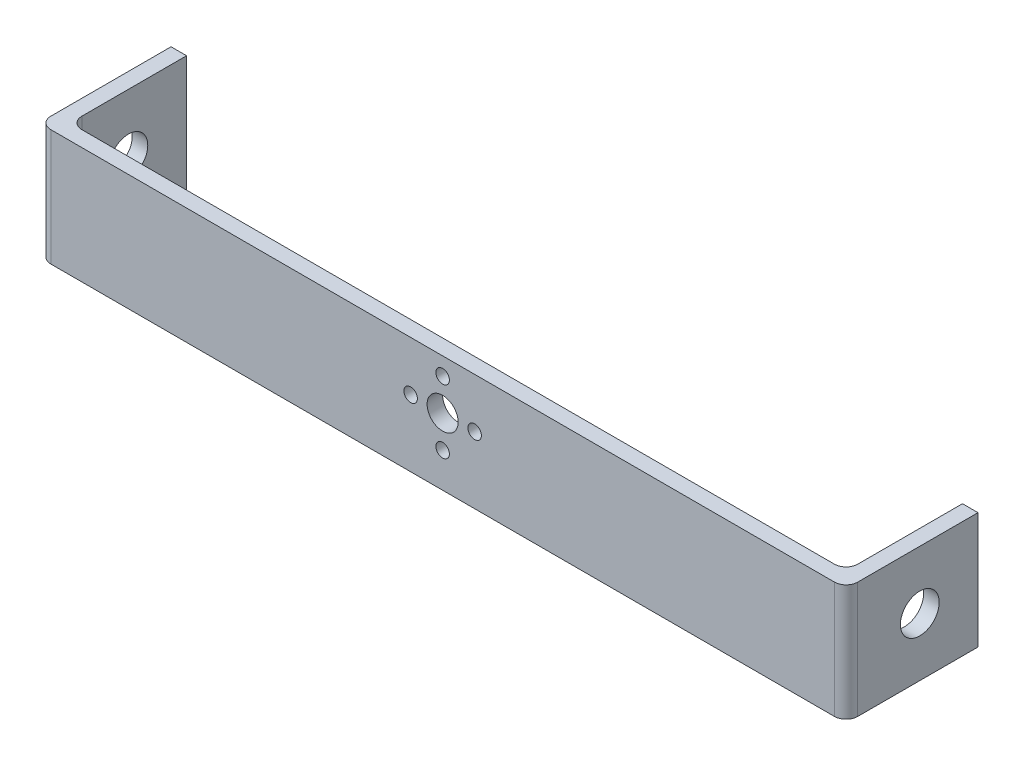
from build123d import *

# Parameters (mm, degrees)
SURFACE_EXTRUDE1_1_DEPTH = 30
THICKEN2_T2              = 4
SURFACE_EXTRUDE2_2_DEPTH = 20
THICKEN3_T2              = 4
FILLET1_R                = 3
SKETCH3_R                = 5
CUT_EXTRUDE1_DEPTH       = 217.018517725
CUT_EXTRUDE1_DEPTH_BACK  = 217.018517725
SKETCH4_R                = 4
CUT_EXTRUDE3_DEPTH       = 10
SKETCH5_R                = 1.75
CUT_EXTRUDE4_DEPTH       = 10
CIRPATTERN1_COUNT        = 4
SKETCH6_W                = 50
SKETCH6_H                = 20
CUT_EXTRUDE5_DEPTH       = 10


with BuildPart() as body_1:
    # Surface-Extrude1: a surface, the sketch's curves swept straight by 30 mm
    with BuildLine(Plane(origin=(0, 0, 0), x_dir=(1, 0, 0), z_dir=(0, 1, 0)), mode=Mode.PRIVATE) as surface_extrude1_1_path:
        Line((-100, 30), (-100, 0))
        Line((-100, 0), (100, 0))
        Line((100, 0), (100, 30))
    surface_extrude1_1 = Shell.extrude(surface_extrude1_1_path.wire(), (0 * SURFACE_EXTRUDE1_1_DEPTH, 1 * SURFACE_EXTRUDE1_1_DEPTH, 0 * SURFACE_EXTRUDE1_1_DEPTH))
    add(Solid.thicken(surface_extrude1_1, -THICKEN2_T2))

    # Surface-Extrude2: a surface, the sketch's curves swept straight by 20 mm
    with BuildLine(Plane(origin=(0, 30, 0), x_dir=(1, 0, 0), z_dir=(0, 1, 0)), mode=Mode.PRIVATE) as surface_extrude2_2_path:
        Line((-25, 0), (25, 0))
    surface_extrude2_2 = Shell.extrude(surface_extrude2_2_path.wire(), (0 * SURFACE_EXTRUDE2_2_DEPTH, 1 * SURFACE_EXTRUDE2_2_DEPTH, 0 * SURFACE_EXTRUDE2_2_DEPTH))
    add(Solid.thicken(surface_extrude2_2, -THICKEN3_T2))

    # Fillet1
    fillet1_edges = [body_1.edges().sort_by_distance(p)[0] for p in [
        (-100, 15, 0),
        (100, 15, 0),
        (104, 15, 4),
        (-104, 15, 4),
    ]]
    fillet(fillet1_edges, radius=FILLET1_R)

    # Sketch3 → Cut-Extrude1 (cut, two sides)
    with BuildSketch(Plane(origin=(104, 0, 0), x_dir=(0, 0, -1), z_dir=(1, 0, 0))) as cut_extrude1_sk:
        with Locations((14.996831486, 15)):
            Circle(SKETCH3_R)
    extrude(amount=CUT_EXTRUDE1_DEPTH, mode=Mode.SUBTRACT)
    extrude(cut_extrude1_sk.sketch, amount=-CUT_EXTRUDE1_DEPTH_BACK, mode=Mode.SUBTRACT)

    # Sketch4 → Cut-Extrude3 (cut)
    with BuildSketch(Plane(origin=(0, 0, 0), x_dir=(-1, 0, 0), z_dir=(0, 0, -1))):
        with Locations((0, 17.2)):
            Circle(SKETCH4_R)
    extrude(amount=-CUT_EXTRUDE3_DEPTH, mode=Mode.SUBTRACT)

    # Sketch5 → Cut-Extrude4 (cut)
    with BuildSketch(Plane(origin=(0, 0, 0), x_dir=(-1, 0, 0), z_dir=(0, 0, -1))):
        with Locations((0, 25.45)):
            Circle(SKETCH5_R)
    cut_extrude4 = extrude(amount=-CUT_EXTRUDE4_DEPTH, mode=Mode.SUBTRACT)

    # CirPattern1: Cut-Extrude4 ×4 about axis
    cirpattern1_axis = Axis((0, 17.2, 0), (0, 0, 1))
    for i in range(1, CIRPATTERN1_COUNT):
        add(cut_extrude4.rotate(cirpattern1_axis, i * 360 / CIRPATTERN1_COUNT), mode=Mode.SUBTRACT)

    # Sketch6 → Cut-Extrude5 (cut)
    with BuildSketch(Plane(origin=(0, 0, 0), x_dir=(-1, 0, 0), z_dir=(0, 0, -1))):
        with Locations((0, 40)):
            Rectangle(SKETCH6_W, SKETCH6_H)
    extrude(amount=-CUT_EXTRUDE5_DEPTH, mode=Mode.SUBTRACT)


solid = body_1.part
